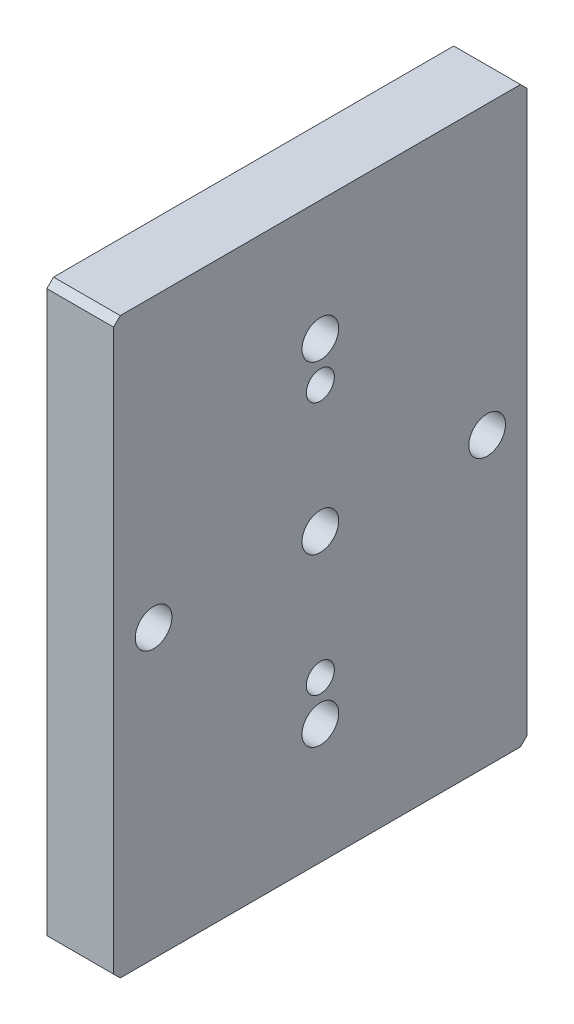
from build123d import *

# Parameters (mm, degrees)
SKETCH_1_W                = 62
SKETCH_1_H                = 86
EXTRUDE_1_DEPTH           = 10
CHAMFER_1_SIZE            = 1
HOLE_WIZARD_1_D           = 5.5
HOLE_WIZARD_1_CBORE_D     = 10
HOLE_WIZARD_1_CBORE_DEPTH = 5.5
HOLE_WIZARD_M5_1_D        = 4.2


with BuildPart() as part:
    # 草图1 → 凸台-拉伸1 (new body)
    with BuildSketch(Plane(origin=(0, 0, 0), x_dir=(0, 0, -1), z_dir=(1, 0, 0))):
        Rectangle(SKETCH_1_W, SKETCH_1_H)
    extrude(amount=EXTRUDE_1_DEPTH)

    # 倒角1
    chamfer_1_edges = [part.edges().sort_by_distance(p)[0] for p in [
        (5, 43, 31),
        (5, 43, -31),
        (5, -43, -31),
        (5, -43, 31),
    ]]
    chamfer(chamfer_1_edges, length=CHAMFER_1_SIZE)

    # 打孔尺寸(%根据)内六角圆柱头螺钉的类型1 (through all)
    with Locations(Plane.ZY):
        with Locations((25, 0), (0, -25), (-25, 0), (0, 25), (0, 0)):
            CounterBoreHole(HOLE_WIZARD_1_D / 2, HOLE_WIZARD_1_CBORE_D / 2, HOLE_WIZARD_1_CBORE_DEPTH)

    # M5 螺纹孔1 (through all)
    with Locations(Plane.ZY):
        with Locations((0, 19), (0, -19)):
            Hole(HOLE_WIZARD_M5_1_D / 2)


solid = part.part
